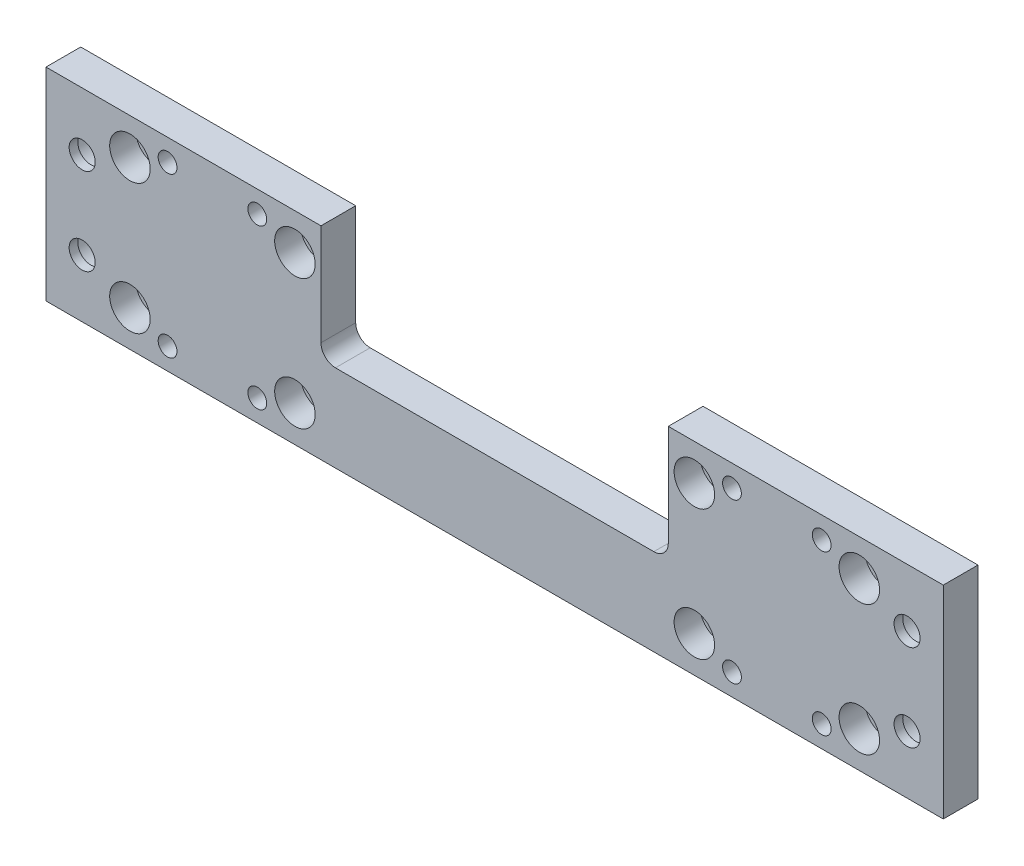
from build123d import *

# Parameters (mm, degrees)
SKETCH_1_W                  = 310
SKETCH_1_H                  = 40
EXTRUDE_1_DEPTH             = 12
SKETCH_8_W                  = 95
SKETCH_8_H                  = 15
SKETCH_8_W_2                = 310
EXTRUDE_2_DEPTH             = 12
HOLE_WIZARD_2_D             = 9
HOLE_WIZARD_2_CBORE_D       = 14
HOLE_WIZARD_2_CBORE_DEPTH   = 9
HOLE_WIZARD_2_2_D           = 9
HOLE_WIZARD_2_2_CBORE_D     = 14
HOLE_WIZARD_2_2_CBORE_DEPTH = 9
HOLE_WIZARD_3_D             = 6.5
HOLE_WIZARD_3_CBORE_D       = 11
HOLE_WIZARD_3_CBORE_DEPTH   = 7
CUT_EXTRUDE_1_DEPTH         = 13


with BuildPart() as part:
    # 草图1 → 凸台-拉伸1 (new body)
    with BuildSketch(Plane.XY):
        Rectangle(SKETCH_1_W, SKETCH_1_H)
    extrude(amount=EXTRUDE_1_DEPTH)

    # 草图8 → 凸台-拉伸2 (add)
    with BuildSketch(Plane.XY.offset(12)):
        with Locations((-107.5, 27.5)):
            Rectangle(SKETCH_8_W, SKETCH_8_H)
        with Locations((107.5, 27.5)):
            Rectangle(SKETCH_8_W, SKETCH_8_H)
        with Locations((0, -27.5)):
            Rectangle(SKETCH_8_W_2, SKETCH_8_H)
    extrude(amount=-EXTRUDE_2_DEPTH)

    # Hole Wizard 2 (through all)
    with Locations(Plane.XY.offset(12)):
        with Locations((-126, 22.5), (-69, 22.5), (-69, -22.5), (-126, -22.5), (126, -22.5), (69, -22.5), (69, 22.5), (126, 22.5)):
            CounterBoreHole(HOLE_WIZARD_2_D / 2, HOLE_WIZARD_2_CBORE_D / 2, HOLE_WIZARD_2_CBORE_DEPTH)

    # Hole Wizard 2 2 (through all)
    with Locations(Plane(origin=(0, 0, 0), x_dir=(-1, 0, 0), z_dir=(0, 0, -1))):
        with Locations((-142.5, 15), (-142.5, -15), (142.5, -15), (142.5, 15)):
            CounterBoreHole(HOLE_WIZARD_2_2_D / 2, HOLE_WIZARD_2_2_CBORE_D / 2, HOLE_WIZARD_2_2_CBORE_DEPTH)

    # 打孔尺寸(%根据)内六角圆柱头螺钉的类型3 (through all)
    with Locations(Plane(origin=(0, 0, 0), x_dir=(-1, 0, 0), z_dir=(0, 0, -1))):
        with Locations((-82, 27.5), (-113, 27.5), (-113, -27.5), (-82, -27.5), (82, -27.5), (113, -27.5), (113, 27.5), (82, 27.5)):
            CounterBoreHole(HOLE_WIZARD_3_D / 2, HOLE_WIZARD_3_CBORE_D / 2, HOLE_WIZARD_3_CBORE_DEPTH)

    # 草图11 → 切除-拉伸1 (cut, through all)
    with BuildSketch(Plane.XY.offset(12)):
        with BuildLine():
            Line((-60, 20), (60, 20))
            Line((60, 20), (60, 0))
            ThreePointArc((60, 0), (58.535533906, -3.535533906), (55, -5))
            Line((55, -5), (-55, -5))
            ThreePointArc((-55, -5), (-58.535533906, -3.535533906), (-60, 0))
            Line((-60, 0), (-60, 20))
        make_face()
    extrude(amount=-CUT_EXTRUDE_1_DEPTH, mode=Mode.SUBTRACT)


solid = part.part
